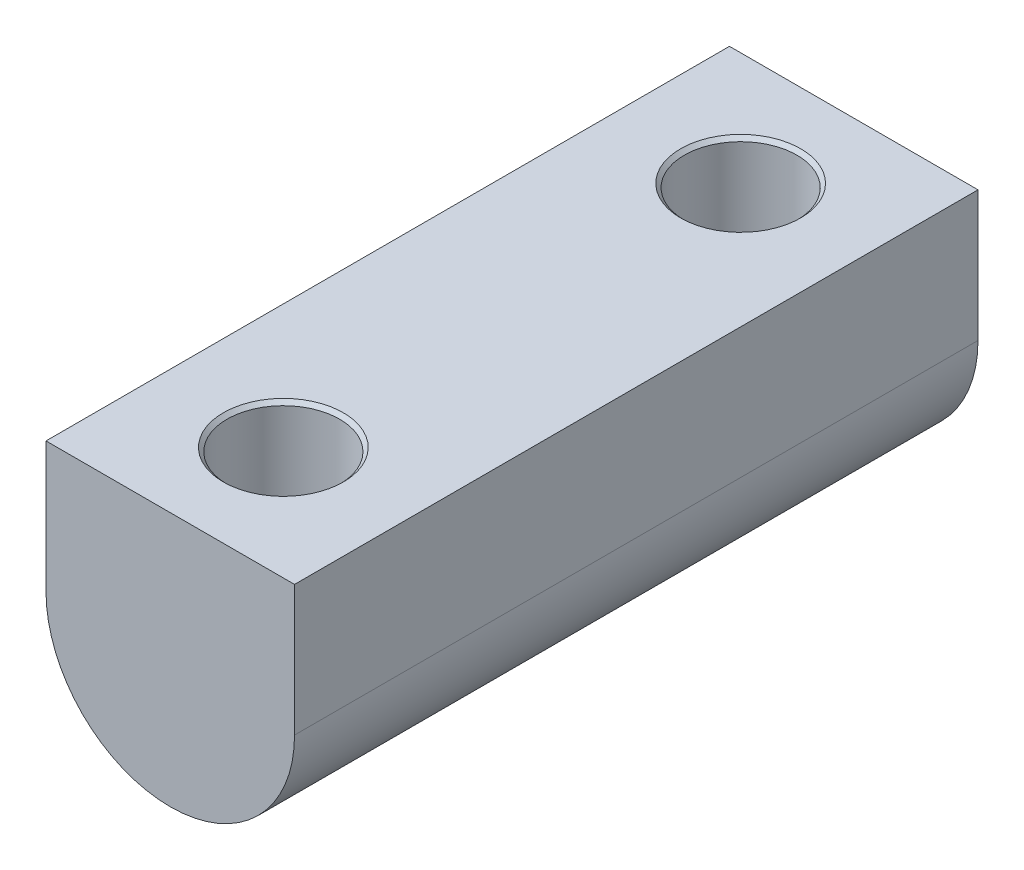
from build123d import *

# Parameters (mm, degrees)
EXTRUDE1_DEPTH                            = 139.7
F_29_32_0_90625_DIAMETER_HOLE1_AT_2_COUNT = 2
F_29_32_0_90625_DIAMETER_HOLE1_AT_2_PITCH = 93.472


with BuildPart() as part:
    # Sketch1 → Extrude1 (new body)
    with BuildSketch(Plane.XY):
        with BuildLine():
            Line((-25.4, 0), (-25.4, 26.67))
            Line((-25.4, 26.67), (25.4, 26.67))
            Line((25.4, 26.67), (25.4, 0))
            ThreePointArc((25.4, 0), (0, -25.4), (-25.4, 0))
        make_face()
    extrude(amount=EXTRUDE1_DEPTH)

    # Sketch2 → 29/32 (0.90625) Diameter Hole1 (revolve, cut)
    with BuildSketch(Plane(origin=(0, 26.67, 23.114), x_dir=(0, 0, 1), z_dir=(1, 0, 0))):
        Polygon((0, 0), (0, 52.07), (12.2682, 52.07), (11.509375, 51.311175), (11.509375, 0.758825), (12.2682, 0), align=None)
    f_29_32_0_90625_diameter_hole1 = revolve(axis=Axis((0, 33.02, 23.114), (0, -1, 0)), mode=Mode.SUBTRACT)

    # 29/32 (0.90625) Diameter Hole1 at 2: 29/32 (0.90625) Diameter Hole1 ×2
    with Locations(*[(0, 0, i * F_29_32_0_90625_DIAMETER_HOLE1_AT_2_PITCH) for i in range(1, F_29_32_0_90625_DIAMETER_HOLE1_AT_2_COUNT)]):
        add(f_29_32_0_90625_diameter_hole1, mode=Mode.SUBTRACT)


solid = part.part
